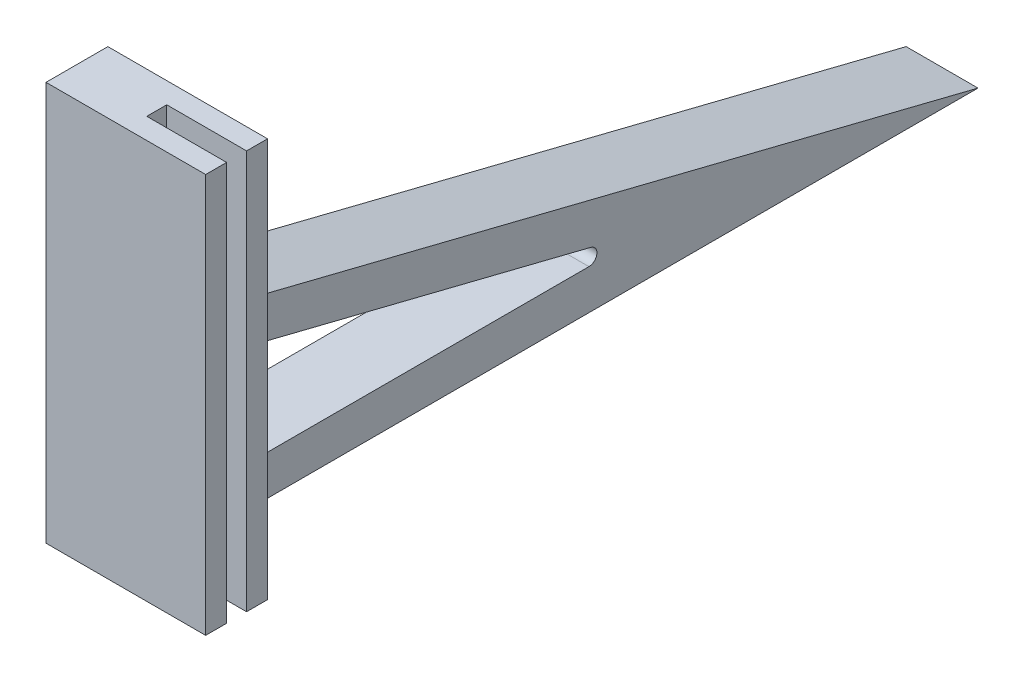
from build123d import *

# Parameters (mm, degrees)
BOSS_EXTRUDE1_DEPTH = 100
EXTRUDE_THIN1_DEPTH = 18
FILLET1_R           = 3
FILLET2_R           = 3
FILLET3_R           = 2
FILLET4_R           = 2
CUT_EXTRUDE1_REACH  = 17.5
SKETCH3_R           = 2.5


with BuildPart() as part:
    # Sketch1 → Boss-Extrude1 (new body)
    with BuildSketch(Plane(origin=(0, 0, 0), x_dir=(1, 0, 0), z_dir=(0, 1, 0))):
        Polygon((0, 0), (20, 0), (20, -5.25), (-20, -5.25), (-20, 10.25), (20, 10.25), (20, 5), (0, 5), align=None)
    extrude(amount=BOSS_EXTRUDE1_DEPTH)

    # Sketch2 → Extrude-Thin1 (add)
    with BuildSketch(Plane.ZY.offset(20)):
        Polygon((-10.25, 0), (-210.25, 0), (-10.25, 50), (-7.82464375, 40.298574999), (-129.018943744, 10), (-10.25, 10), align=None)
    extrude(amount=-EXTRUDE_THIN1_DEPTH)

    # Fillet1
    fillet1_edges = [part.edges().sort_by_distance(p)[0] for p in [
        (-11, 50, -10.25),
    ]]
    fillet(fillet1_edges, radius=FILLET1_R)

    # Fillet2
    fillet2_edges = [part.edges().sort_by_distance(p)[0] for p in [
        (-11, 10, -10.25),
    ]]
    fillet(fillet2_edges, radius=FILLET2_R)

    # Fillet3
    fillet3_edges = [part.edges().sort_by_distance(p)[0] for p in [
        (-11, 39.692235936, -10.25),
    ]]
    fillet(fillet3_edges, radius=FILLET3_R)

    # Fillet4
    fillet4_edges = [part.edges().sort_by_distance(p)[0] for p in [
        (-11, 10, -129.018943744),
    ]]
    fillet(fillet4_edges, radius=FILLET4_R)

    # Sketch3 → Cut-Extrude1 (cut, up to next)
    with BuildSketch(Plane(origin=(0, 0, -10.25), x_dir=(-1, 0, 0), z_dir=(0, 0, -1)), mode=Mode.PRIVATE) as cut_extrude1_sk1:
        with Locations((-10, 50)):
            Circle(SKETCH3_R)
    cut_extrude1_tool1 = extrude(cut_extrude1_sk1.sketch, amount=-CUT_EXTRUDE1_REACH, mode=Mode.PRIVATE) & part.part
    add(cut_extrude1_tool1.solids().sort_by_distance((10, 50, -10.25))[0], mode=Mode.SUBTRACT)


solid = part.part
